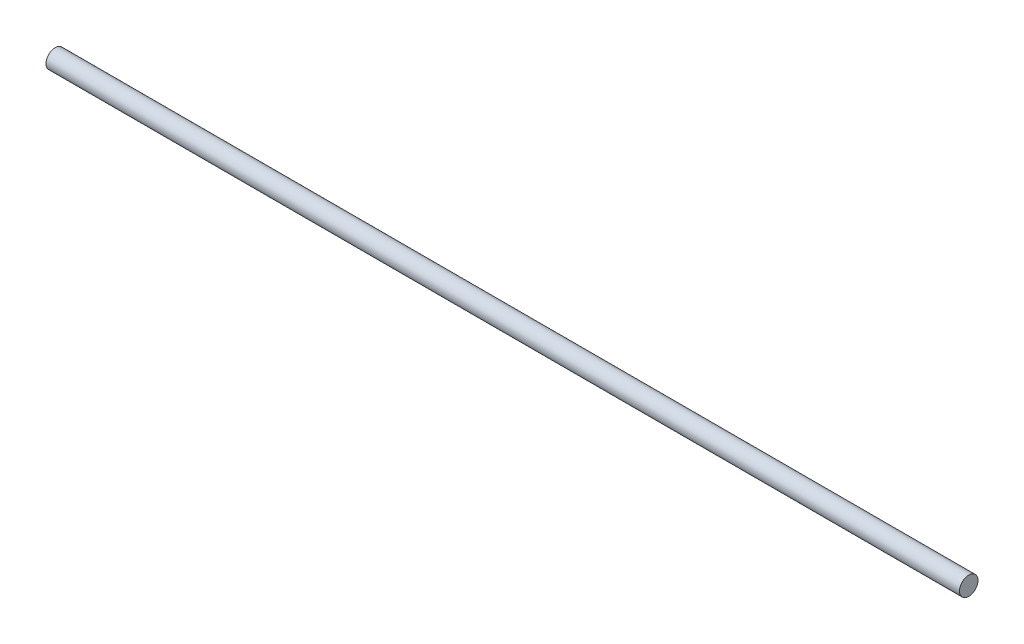
from build123d import *

# Parameters (mm, degrees)
CROQUIS1_R              = 4
SALIENTE_EXTRUIR1_DEPTH = 395.00687984


with BuildPart() as part:
    # Croquis1 → Saliente-Extruir1 (new body)
    with BuildSketch(Plane(origin=(0, 0, 0), x_dir=(0, 0, -1), z_dir=(1, 0, 0))):
        Circle(CROQUIS1_R)
    extrude(amount=SALIENTE_EXTRUIR1_DEPTH)


solid = part.part
